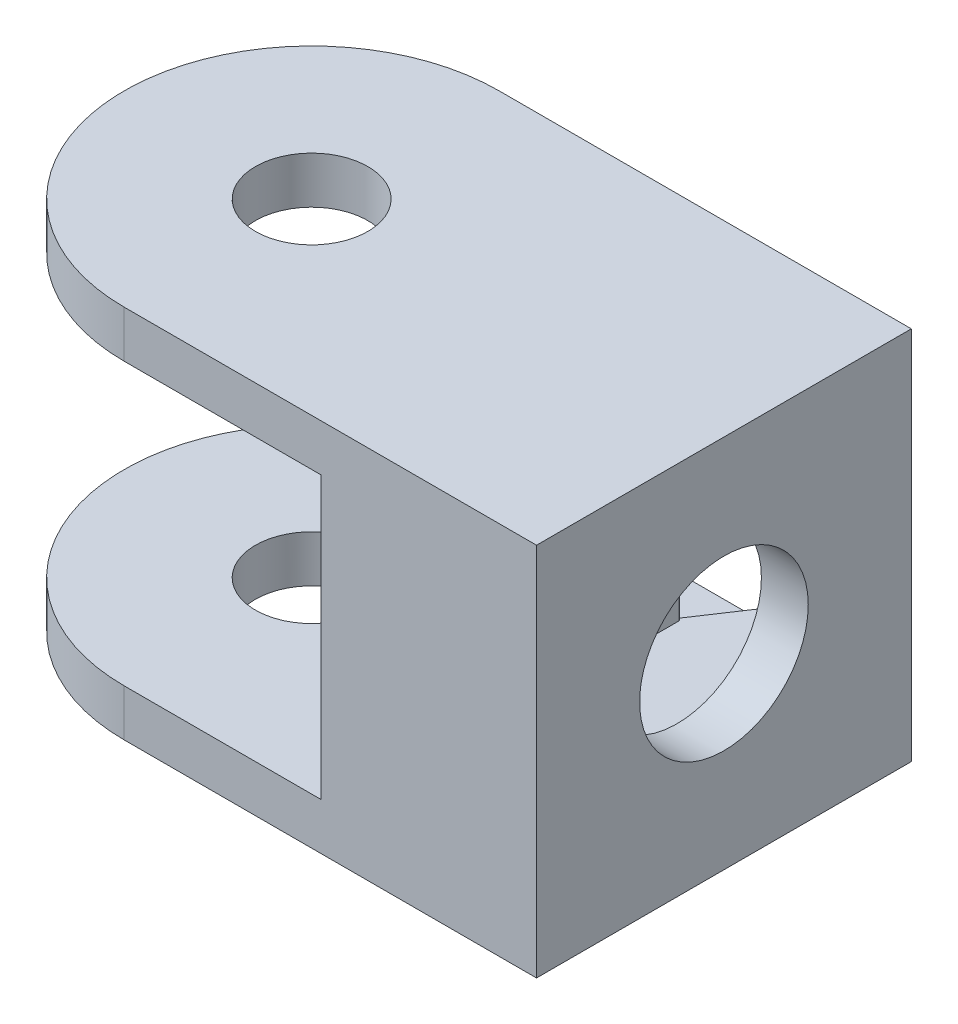
from build123d import *

# Parameters (mm, degrees)
SKETCH1_R           = 3
BOSS_EXTRUDE1_DEPTH = 20
SKETCH4_W           = 7
SKETCH4_H           = 13.6
CUT_EXTRUDE3_DEPTH  = 17
CUT_EXTRUDE4_REACH  = 34
SKETCH5_R           = 4.5
SKETCH7_W           = 15
SKETCH7_H           = 20
CUT_EXTRUDE5_DEPTH  = 10.5
CUT_EXTRUDE6_START  = -2.5
CUT_EXTRUDE6_DEPTH  = 15
FILLET1_R           = 0.1


with BuildPart() as part:
    # Sketch1 → Boss-Extrude1 (new body)
    with BuildSketch(Plane(origin=(0, 0, 0), x_dir=(1, 0, 0), z_dir=(0, 1, 0))):
        with BuildLine():
            Line((-11, -10), (11, -10))
            Line((11, -10), (11, 10))
            Line((11, 10), (-11, 10))
            ThreePointArc((-11, 10), (-21, 0), (-11, -10))
        make_face()
        with Locations((-11, 0)):
            Circle(SKETCH1_R, mode=Mode.SUBTRACT)
    extrude(amount=BOSS_EXTRUDE1_DEPTH)

    # Sketch4 → Cut-Extrude3 (cut)
    with BuildSketch(Plane(origin=(0, 0, -10), x_dir=(-1, 0, 0), z_dir=(0, 0, -1))):
        with Locations((-5, 10)):
            Rectangle(SKETCH4_W, SKETCH4_H)
    extrude(amount=-CUT_EXTRUDE3_DEPTH, mode=Mode.SUBTRACT)

    # Sketch5 → Cut-Extrude4 (cut, up to next)
    with BuildSketch(Plane(origin=(11, 0, 0), x_dir=(0, 0, -1), z_dir=(1, 0, 0)), mode=Mode.PRIVATE) as cut_extrude4_sk1:
        with Locations((0, 10)):
            Circle(SKETCH5_R)
    cut_extrude4_tool1 = extrude(cut_extrude4_sk1.sketch, amount=-CUT_EXTRUDE4_REACH, mode=Mode.PRIVATE) & part.part
    add(cut_extrude4_tool1.solids().sort_by_distance((11, 10, 0))[0], mode=Mode.SUBTRACT)

    # Sketch7 → Cut-Extrude5 (cut, symmetric)
    with BuildSketch(Plane(origin=(-11, 0, 0), x_dir=(0, -1, 0), z_dir=(1, 0, 0))):
        with Locations((-10, 0)):
            Rectangle(SKETCH7_W, SKETCH7_H)
    extrude(amount=CUT_EXTRUDE5_DEPTH, both=True, mode=Mode.SUBTRACT)

    # Sketch8 → Cut-Extrude6 (cut)
    with BuildSketch(Plane.XZ.offset(CUT_EXTRUDE6_START)):
        Polygon((3.215058798, -10), (-0.5, -4.410536459), (-0.5, -10), align=None)
    extrude(amount=-CUT_EXTRUDE6_DEPTH, mode=Mode.SUBTRACT)

    # Fillet1
    fillet1_edges = [part.edges().sort_by_distance(p)[0] for p in [
        (1.5, 10, -7.419621291),
    ]]
    fillet(fillet1_edges, radius=FILLET1_R)


solid = part.part
